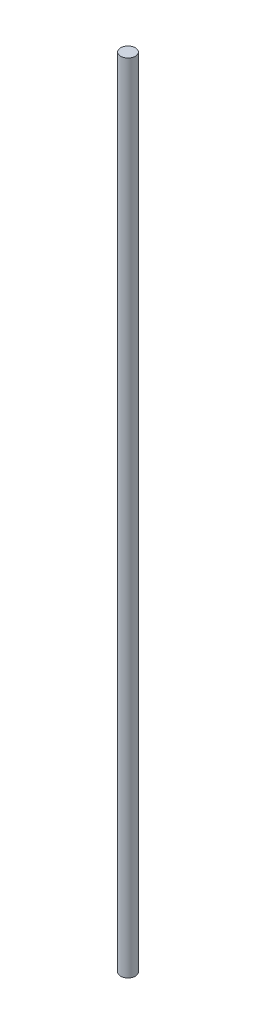
from build123d import *

# Parameters (mm, degrees)
SKETCH3_R           = 12
BOSS_EXTRUDE1_DEPTH = 1300


with BuildPart() as part:
    # Sketch3 → Boss-Extrude1 (new body)
    with BuildSketch(Plane(origin=(0, 0, 0), x_dir=(1, 0, 0), z_dir=(0, 1, 0))):
        Circle(SKETCH3_R)
    extrude(amount=BOSS_EXTRUDE1_DEPTH)


solid = part.part
